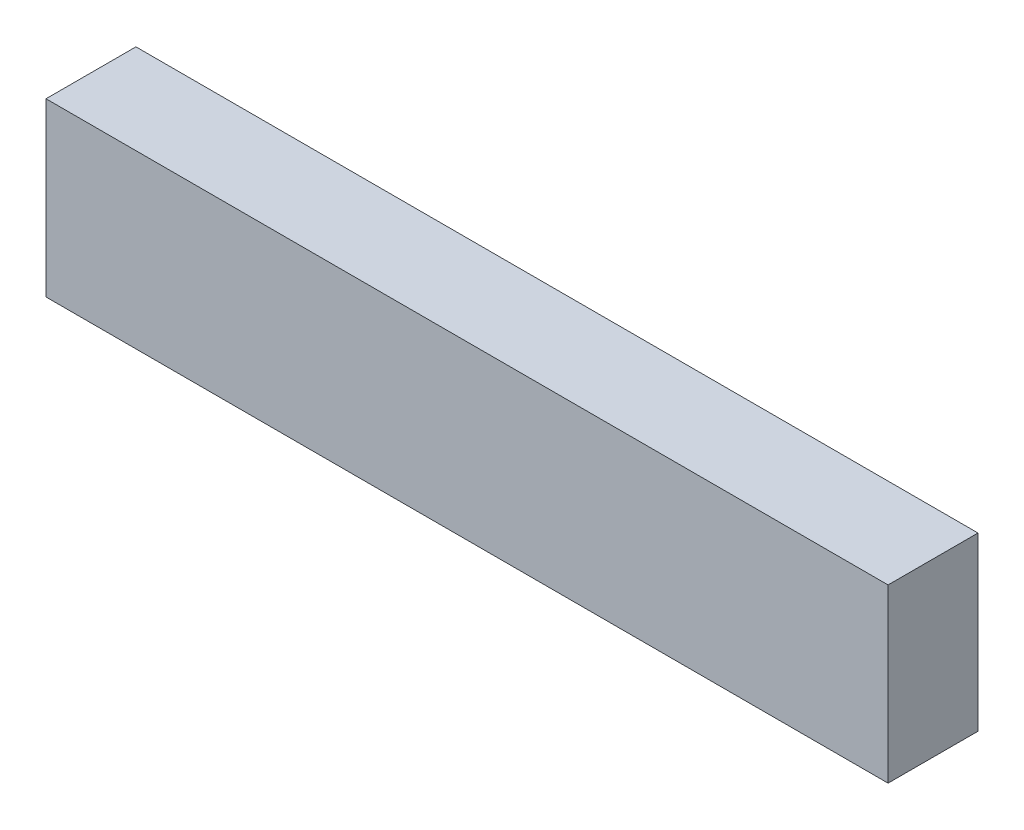
from build123d import *

# Parameters (mm, degrees)
SKETCH2_W           = 327.025
SKETCH2_H           = 34.925
BOSS_EXTRUDE1_DEPTH = 66.675


with BuildPart() as part:
    # Sketch2 → Boss-Extrude1 (new body)
    with BuildSketch(Plane(origin=(0, 0, 0), x_dir=(1, 0, 0), z_dir=(0, 1, 0))):
        with Locations((163.5125, 17.4625)):
            Rectangle(SKETCH2_W, SKETCH2_H)
    extrude(amount=BOSS_EXTRUDE1_DEPTH)


solid = part.part
